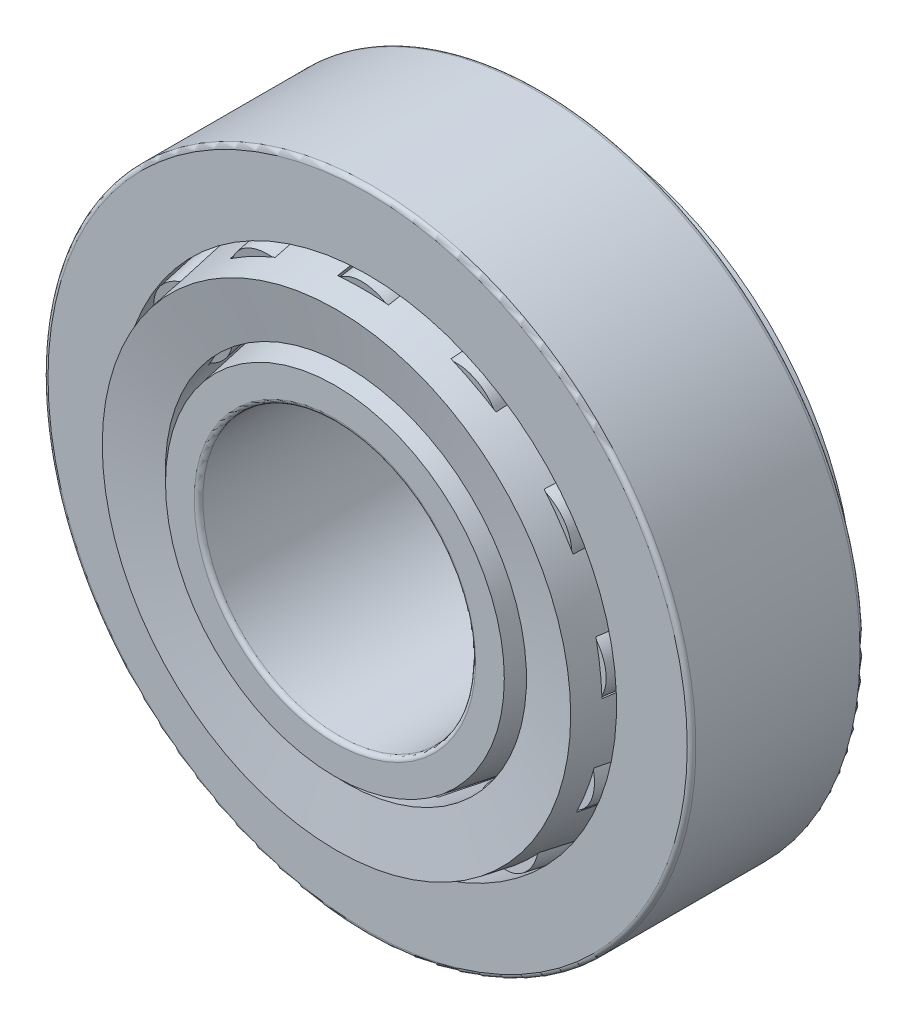
from build123d import *

# Parameters (mm, degrees)
CIRPATTERN2_COUNT = 13
CIRPATTERN1_COUNT = 13
FILLET1_R         = 0.301625
FILLET2_R         = 0.301625


with BuildPart() as part:
    # Sketch1 → Revolve1 (revolve)
    with BuildSketch(Plane(origin=(0, 0, 0), x_dir=(0, 0, -1), z_dir=(1, 0, 0))):
        Polygon((-6.0325, 22.621875), (6.0325, 22.621875), (6.0325, 19.510510022), (-6.0325, 17.383125), align=None)
    revolve(axis=Axis((0, 0, 8.3185), (0, 0, -1)))

    # Fillet1
    fillet1_edges = [part.edges().sort_by_distance(p)[0] for p in [
        (0, -22.621875, -6.0325),
        (0, -22.621875, 6.0325),
    ]]
    fillet(fillet1_edges, radius=FILLET1_R)


with BuildPart() as body_2:
    # Sketch5 → Revolve4 (revolve)
    with BuildSketch(Plane(origin=(0, 0, 0), x_dir=(0, 0, -1), z_dir=(1, 0, 0))):
        Polygon((8.3185, 14.76375), (-8.3185, 11.830198022), (-8.3185, 9.525), (8.3185, 9.525), align=None)
    revolve(axis=Axis((0, 0, 8.3185), (0, 0, -1)))

    # Fillet2
    fillet2_edges = [body_2.edges().sort_by_distance(p)[0] for p in [
        (0, -9.525, -8.3185),
        (0, -9.525, 8.3185),
    ]]
    fillet(fillet2_edges, radius=FILLET2_R)


with BuildPart() as body_3:
    # Sketch2 → Revolve2 (revolve)
    with BuildSketch(Plane(origin=(0, 0, 0), x_dir=(0, 0, -1), z_dir=(1, 0, 0))):
        Polygon((-8.208415612, 16.355721932), (-7.547909282, 12.609804394), (6.0325, 15.00439696), (9.224415612, 15.567217802), (8.563909282, 19.31313534), (6.0325, 18.866779585), align=None)
    revolve(axis=Axis((0, 0, 8.3185), (0, 0, -1)))

    # Sketch3 → Cut-Revolve1 (revolve, cut)
    with BuildSketch(Plane(origin=(0, 0, 0), x_dir=(0, 0, -1), z_dir=(1, 0, 0))):
        Polygon((-6.0325, 14.80820325), (-6.472837553, 17.305481609), (5.592162447, 19.432866631), (6.0325, 16.935588272), align=None)
    cut_revolve1 = revolve(axis=Axis((0, 14.482763163, 7.878162447), (0, 0.17364817766692706, -0.9848077530122087)), mode=Mode.SUBTRACT)

    # CirPattern1: Cut-Revolve1 ×13 about axis
    cirpattern1_axis = Axis((0, 0, -8.3185), (0, 0, 1))
    for i in range(1, CIRPATTERN1_COUNT):
        add(cut_revolve1.rotate(cirpattern1_axis, i * 360 / CIRPATTERN1_COUNT), mode=Mode.SUBTRACT)


with BuildPart() as body_4:
    # Sketch4 → Revolve3 (revolve)
    with BuildSketch(Plane(origin=(0, 0, 0), x_dir=(0, 0, -1), z_dir=(1, 0, 0))):
        Polygon((-6.450784234, 17.180411024), (5.614215766, 19.307796046), (6.0325, 16.935588272), (-6.0325, 14.80820325), align=None)
    revolve(axis=Axis((0, 14.482763163, 7.878162447), (0, 0.17364817766692706, -0.9848077530122087)))


with BuildPart() as cirpattern2_1:
    # CirPattern2: pattern copy
    add(body_4.part.rotate(Axis((0, 0, -8.3185), (0, 0, 1)), 1 * 360 / CIRPATTERN2_COUNT))


with BuildPart() as cirpattern2_2:
    # CirPattern2: pattern copy
    add(body_4.part.rotate(Axis((0, 0, -8.3185), (0, 0, 1)), 2 * 360 / CIRPATTERN2_COUNT))


with BuildPart() as cirpattern2_3:
    # CirPattern2: pattern copy
    add(body_4.part.rotate(Axis((0, 0, -8.3185), (0, 0, 1)), 3 * 360 / CIRPATTERN2_COUNT))


with BuildPart() as cirpattern2_4:
    # CirPattern2: pattern copy
    add(body_4.part.rotate(Axis((0, 0, -8.3185), (0, 0, 1)), 4 * 360 / CIRPATTERN2_COUNT))


with BuildPart() as cirpattern2_5:
    # CirPattern2: pattern copy
    add(body_4.part.rotate(Axis((0, 0, -8.3185), (0, 0, 1)), 5 * 360 / CIRPATTERN2_COUNT))


with BuildPart() as cirpattern2_6:
    # CirPattern2: pattern copy
    add(body_4.part.rotate(Axis((0, 0, -8.3185), (0, 0, 1)), 6 * 360 / CIRPATTERN2_COUNT))


with BuildPart() as cirpattern2_7:
    # CirPattern2: pattern copy
    add(body_4.part.rotate(Axis((0, 0, -8.3185), (0, 0, 1)), 7 * 360 / CIRPATTERN2_COUNT))


with BuildPart() as cirpattern2_8:
    # CirPattern2: pattern copy
    add(body_4.part.rotate(Axis((0, 0, -8.3185), (0, 0, 1)), 8 * 360 / CIRPATTERN2_COUNT))


with BuildPart() as cirpattern2_9:
    # CirPattern2: pattern copy
    add(body_4.part.rotate(Axis((0, 0, -8.3185), (0, 0, 1)), 9 * 360 / CIRPATTERN2_COUNT))


with BuildPart() as cirpattern2_10:
    # CirPattern2: pattern copy
    add(body_4.part.rotate(Axis((0, 0, -8.3185), (0, 0, 1)), 10 * 360 / CIRPATTERN2_COUNT))


with BuildPart() as cirpattern2_11:
    # CirPattern2: pattern copy
    add(body_4.part.rotate(Axis((0, 0, -8.3185), (0, 0, 1)), 11 * 360 / CIRPATTERN2_COUNT))


with BuildPart() as cirpattern2_12:
    # CirPattern2: pattern copy
    add(body_4.part.rotate(Axis((0, 0, -8.3185), (0, 0, 1)), 12 * 360 / CIRPATTERN2_COUNT))


solid = Compound([part.part, body_2.part, body_3.part, body_4.part, cirpattern2_1.part, cirpattern2_2.part, cirpattern2_3.part, cirpattern2_4.part, cirpattern2_5.part, cirpattern2_6.part, cirpattern2_7.part, cirpattern2_8.part, cirpattern2_9.part, cirpattern2_10.part, cirpattern2_11.part, cirpattern2_12.part])
